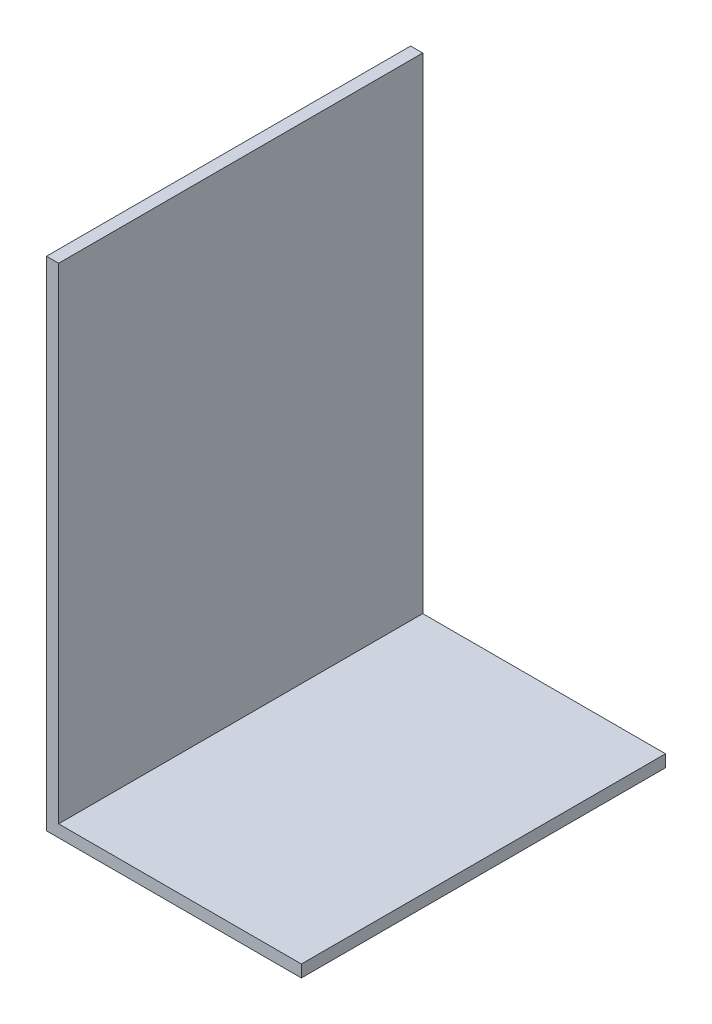
from build123d import *

# Parameters (mm, degrees)
EXTRUDE_THIN1_DEPTH = 15


with BuildPart() as part:
    # Sketch1 → Extrude-Thin1 (new body, symmetric)
    with BuildSketch(Plane.XY):
        Polygon((0, 40), (0, 0), (20, 0), (20, -1), (-1, -1), (-1, 40), align=None)
    extrude(amount=EXTRUDE_THIN1_DEPTH, both=True)


solid = part.part
